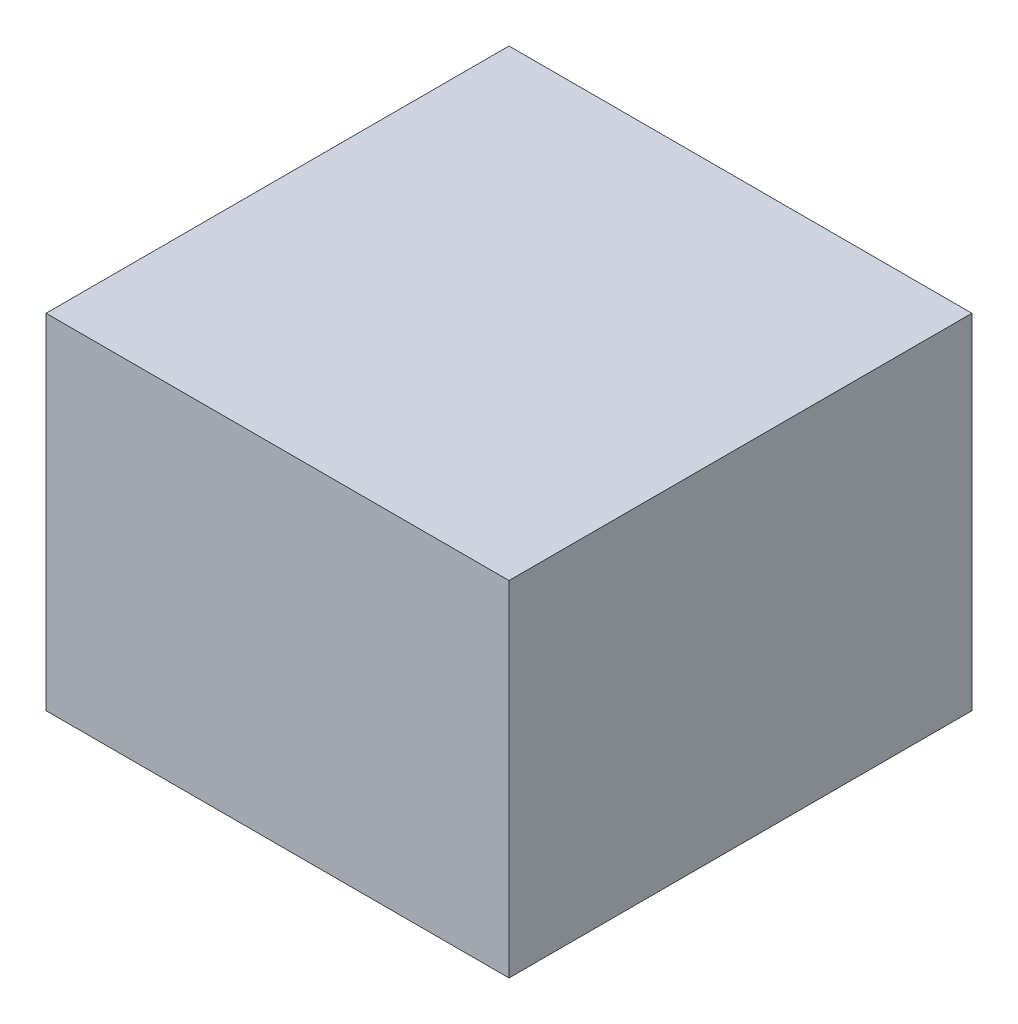
from build123d import *

# Parameters (mm, degrees)
SKETCH1_W           = 15.6
SKETCH1_H           = 15.6
BOSS_EXTRUDE1_DEPTH = 11.6


with BuildPart() as part:
    # Sketch1 → Boss-Extrude1 (new body)
    with BuildSketch(Plane(origin=(0, 0, 0), x_dir=(1, 0, 0), z_dir=(0, 1, 0))):
        with Locations((7.8, 7.8)):
            Rectangle(SKETCH1_W, SKETCH1_H)
    extrude(amount=BOSS_EXTRUDE1_DEPTH)


solid = part.part
